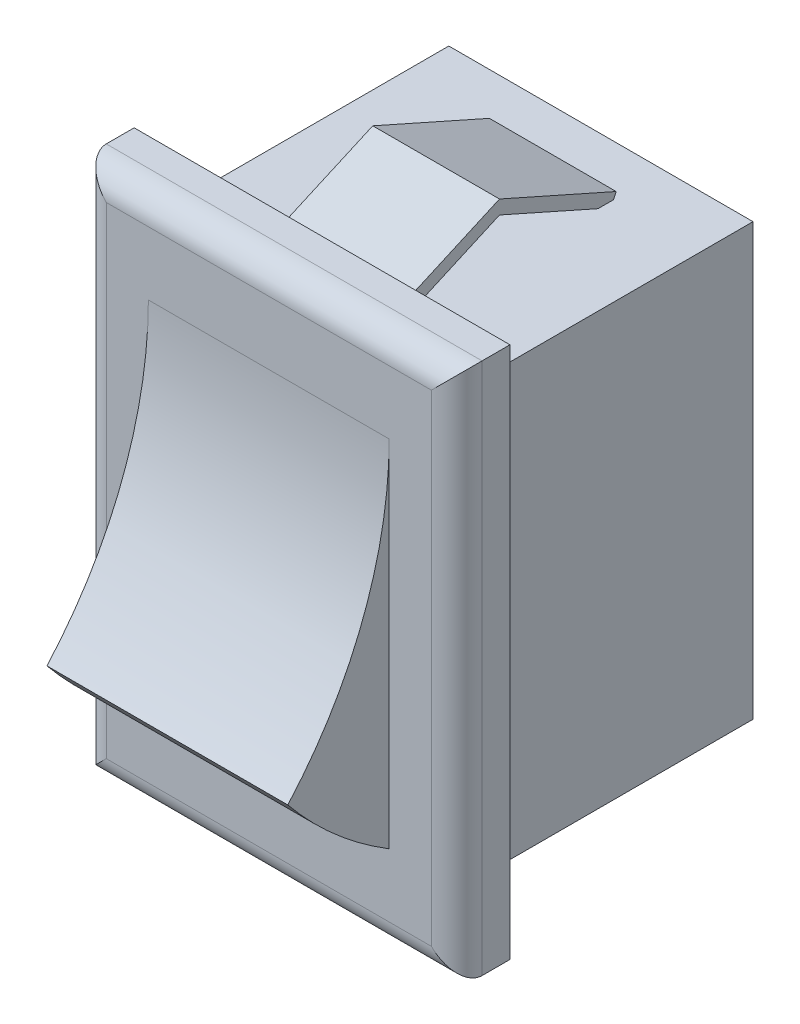
from build123d import *

# Parameters (mm, degrees)
ESQUISSE1_W        = 12
ESQUISSE1_H        = 17
BOSS_EXTRU_1_DEPTH = 11
ESQUISSE2_W        = 14.823529412
ESQUISSE2_H        = 21
BOSS_EXTRU_2_DEPTH = 2.1
BOSS_EXTRU_3_DEPTH = 4.75
EXTRU_MINCE1_DEPTH = 2.5
CONG_1_R           = 1


with BuildPart() as part:
    # Esquisse1 → Boss.-Extru.1 (new body)
    with BuildSketch(Plane.XY):
        Rectangle(ESQUISSE1_W, ESQUISSE1_H)
    extrude(amount=BOSS_EXTRU_1_DEPTH)

    # Esquisse2 → Boss.-Extru.2 (add)
    with BuildSketch(Plane.XY.offset(11)):
        Rectangle(ESQUISSE2_W, ESQUISSE2_H)
    extrude(amount=BOSS_EXTRU_2_DEPTH)

    # Esquisse3 → Boss.-Extru.3 (add, symmetric)
    with BuildSketch(Plane(origin=(0, 0, 0), x_dir=(0, 0, -1), z_dir=(1, 0, 0))):
        with BuildLine():
            Line((-13.1, -7), (-13.1, 7))
            ThreePointArc((-13.1, 7), (-14.133865433, 1.381948736), (-17.1, -3.5))
            ThreePointArc((-17.1, -3.5), (-15.248408263, -5.419609444), (-13.1, -7))
        make_face()
    extrude(amount=BOSS_EXTRU_3_DEPTH, both=True)

    # Esquisse4 → Extru.-Mince1 (add, symmetric)
    with BuildSketch(Plane(origin=(0, 0, 0), x_dir=(0, 0, -1), z_dir=(1, 0, 0))):
        Polygon((-11.101534617, -8.728452887), (-6.5, -10.773579383), (-1.898465383, -8.728452887), (-2.101534617, -8.271547113), (-6.5, -10.226420617), (-10.898465383, -8.271547113), align=None)
        Polygon((-10.898465383, 8.271547113), (-6.5, 10.226420617), (-2.101534617, 8.271547113), (-1.898465383, 8.728452887), (-6.5, 10.773579383), (-11.101534617, 8.728452887), align=None)
    extrude(amount=EXTRU_MINCE1_DEPTH, both=True)

    # Congé1
    cong_1_edges = [part.edges().sort_by_distance(p)[0] for p in [
        (7.411764706, 0, 13.1),
        (0, 10.5, 13.1),
        (-7.411764706, 0, 13.1),
        (0, -10.5, 13.1),
    ]]
    fillet(cong_1_edges, radius=CONG_1_R)


solid = part.part
